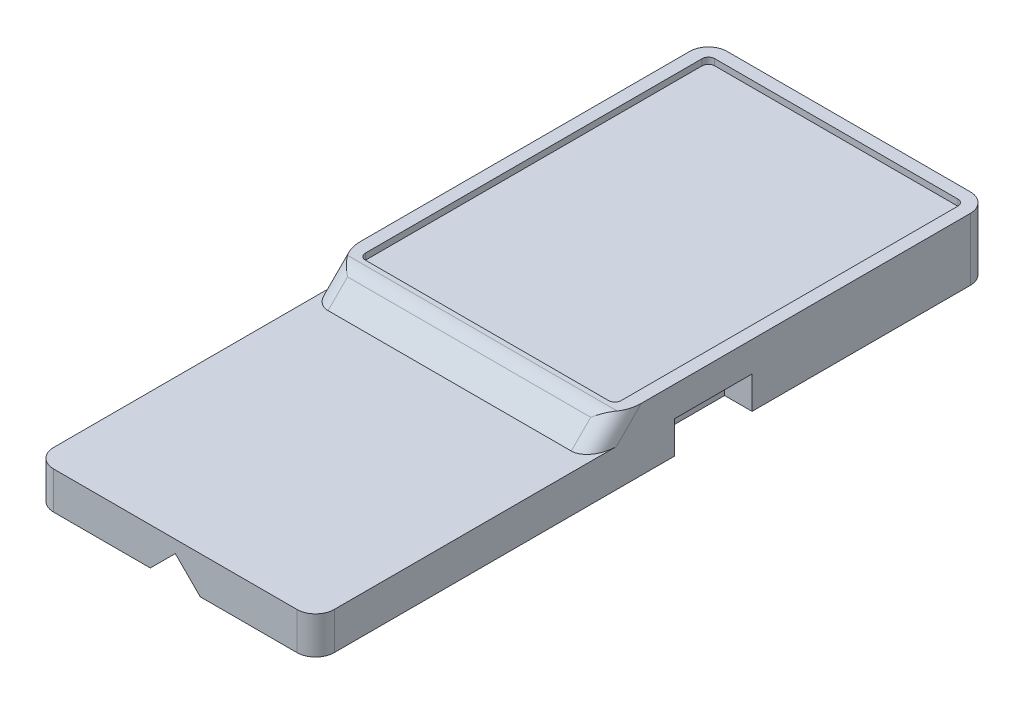
from build123d import *

# Parameters (mm, degrees)
SURFACE_SKETCH_W         = 22.5
SURFACE_SKETCH_H         = 30
BODY_DEPTH               = 4.5
SKETCH_19_W              = 22.5
SKETCH_19_H              = 24
EXTRUDE_4_DEPTH          = 3
FILLET_6_R               = 1.5
MAGNET_CUTOUT_SKETCH_W   = 2.2
MAGNET_CUTOUT_SKETCH_H   = 6.2
MAGNET_CUTOUT_DEPTH      = 2.6
BORDER_DEPTH             = 0.5
CHAMPFER_DEPTH           = 22.5
FILLET_7_R               = 1.5
FILLET_8_R               = 0.5
CUT_EXTRUDE_1_DEPTH      = 23.5
CUT_EXTRUDE_2_DEPTH      = 1
CUT_EXTRUDE_2_DEPTH_BACK = 55


with BuildPart() as part:
    # surface_sketch → body (new body)
    with BuildSketch(Plane(origin=(0, 0, 0), x_dir=(1, 0, 0), z_dir=(0, 1, 0))):
        with Locations((-1.15, 0)):
            Rectangle(SURFACE_SKETCH_W, SURFACE_SKETCH_H)
    extrude(amount=-BODY_DEPTH)

    # Эскиз19 → Бобышка-Вытянуть4 (add)
    with BuildSketch(Plane(origin=(0, -4.5, 0), x_dir=(1, 0, 0), z_dir=(0, 1, 0))):
        with Locations((-1.15, -27)):
            Rectangle(SKETCH_19_W, SKETCH_19_H)
    extrude(amount=EXTRUDE_4_DEPTH)

    # Скругление6
    fillet_6_edges = [part.edges().sort_by_distance(p)[0] for p in [
        (-12.4, -3, 39),
        (10.1, -3, 39),
        (10.1, -2.25, -15),
        (-12.4, -2.25, -15),
    ]]
    fillet(fillet_6_edges, radius=FILLET_6_R)

    # magnet_cutout_sketch → magnet_cutout (cut)
    with BuildSketch(Plane.XZ.offset(4.5)):
        with Locations((9, 7.1)):
            Rectangle(MAGNET_CUTOUT_SKETCH_W, MAGNET_CUTOUT_SKETCH_H)
    magnet_cutout = extrude(amount=-MAGNET_CUTOUT_DEPTH, mode=Mode.SUBTRACT)

    # magnet_cutout_mirror: magnet_cutout across plane
    add(magnet_cutout.mirror(Plane(origin=(-1.15, 0, 0), x_dir=(0, 0, 1), z_dir=(1, 0, 0))), mode=Mode.SUBTRACT)

    # border_sketch → border (add)
    with BuildSketch(Plane(origin=(0, 0, 0), x_dir=(1, 0, 0), z_dir=(0, 1, 0))):
        with BuildLine():
            Line((-12.4, -15), (-12.4, 13.5))
            ThreePointArc((-12.4, 13.5), (-11.960660172, 14.560660172), (-10.9, 15))
            Line((-10.9, 15), (8.6, 15))
            ThreePointArc((8.6, 15), (9.660660172, 14.560660172), (10.1, 13.5))
            Line((10.1, 13.5), (10.1, -15))
            Line((10.1, -15), (9.1, -15))
            Line((9.1, -15), (9.1, 13.5))
            ThreePointArc((9.1, 13.5), (8.953553391, 13.853553391), (8.6, 14))
            Line((8.6, 14), (-10.9, 14))
            ThreePointArc((-10.9, 14), (-11.253553391, 13.853553391), (-11.4, 13.5))
            Line((-11.4, 13.5), (-11.4, -15))
            Line((-11.4, -15), (-12.4, -15))
        make_face()
    extrude(amount=BORDER_DEPTH)

    # Эскиз21 → champfer (add)
    with BuildSketch(Plane.ZY.offset(12.4)):
        Polygon((15, 0.5), (17, -1.5), (15, -1.5), (14, -1.5), (14, 0.5), align=None)
    extrude(amount=-CHAMPFER_DEPTH)

    # Скругление7
    fillet_7_edges = [part.edges().sort_by_distance(p)[0] for p in [
        (-12.4, -0.5, 16),
        (10.1, -0.5, 16),
    ]]
    fillet(fillet_7_edges, radius=FILLET_7_R)

    # Скругление8
    fillet_8_edges = [part.edges().sort_by_distance(p)[0] for p in [
        (9.1, 0.25, 14),
        (-11.4, 0.25, 14),
    ]]
    fillet(fillet_8_edges, radius=FILLET_8_R)

    # Эскиз22 → Вырез-Вытянуть1 (cut, through all)
    with BuildSketch(Plane.ZY.offset(12.4)):
        with BuildLine():
            Line((12.878679656, 0.5), (14.378679656, 0.5))
            ThreePointArc((14.378679656, 0.5), (14.952704805, 0.385819299), (15.439339828, 0.060660172))
            Line((15.439339828, 0.060660172), (17, -1.5))
            Line((17, -1.5), (17.923275361, -1.5))
            Line((17.923275361, -1.5), (15.181180077, 1.242095285))
            Line((15.181180077, 1.242095285), (12.878679656, 1.122407091))
            Line((12.878679656, 1.122407091), (12.878679656, 0.5))
        make_face()
    extrude(amount=-CUT_EXTRUDE_1_DEPTH, mode=Mode.SUBTRACT)

    # Эскиз23 → Вырез-Вытянуть2 (cut, two sides)
    with BuildSketch(Plane(origin=(0, 0, -15), x_dir=(-1, 0, 0), z_dir=(0, 0, -1))) as cut_extrude_2_sk:
        Polygon((1.15, -4.5), (-0.85, -4.5), (1.15, -2.5), (3.15, -4.5), align=None)
    extrude(amount=CUT_EXTRUDE_2_DEPTH, mode=Mode.SUBTRACT)
    extrude(cut_extrude_2_sk.sketch, amount=-CUT_EXTRUDE_2_DEPTH_BACK, mode=Mode.SUBTRACT)


solid = part.part
